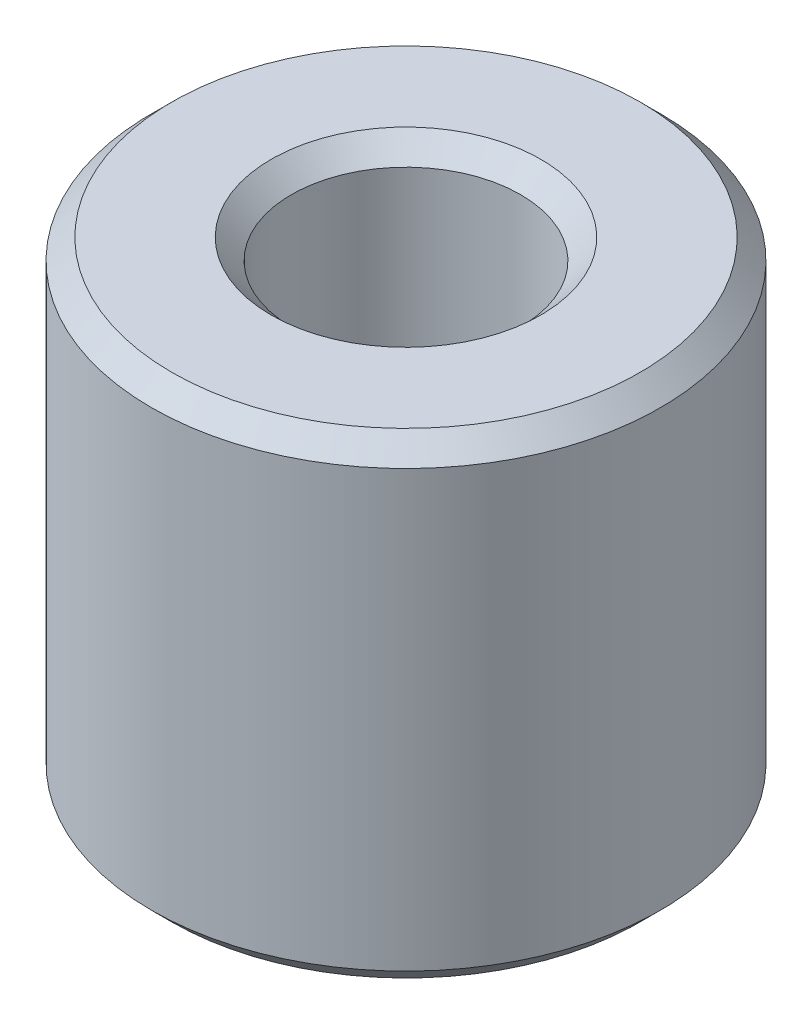
from build123d import *

# Parameters (mm, degrees)
SKETCH1_R        = 10
SKETCH1_R_2      = 4.5
BODY_DEPTH       = 18.7
CHAMFER_0_8_SIZE = 0.8


with BuildPart() as part:
    # Sketch1 → Body (new body)
    with BuildSketch(Plane(origin=(0, 0, 0), x_dir=(1, 0, 0), z_dir=(0, 1, 0))):
        Circle(SKETCH1_R)
        Circle(SKETCH1_R_2, mode=Mode.SUBTRACT)
    extrude(amount=BODY_DEPTH)

    # Chamfer 0.8
    chamfer_0_8_edges = [part.edges().sort_by_distance(p)[0] for p in [
        (-10, 0, 0),
        (-10, 18.7, 0),
        (-4.5, 0, 0),
        (-4.5, 18.7, 0),
    ]]
    chamfer(chamfer_0_8_edges, length=CHAMFER_0_8_SIZE)


solid = part.part
